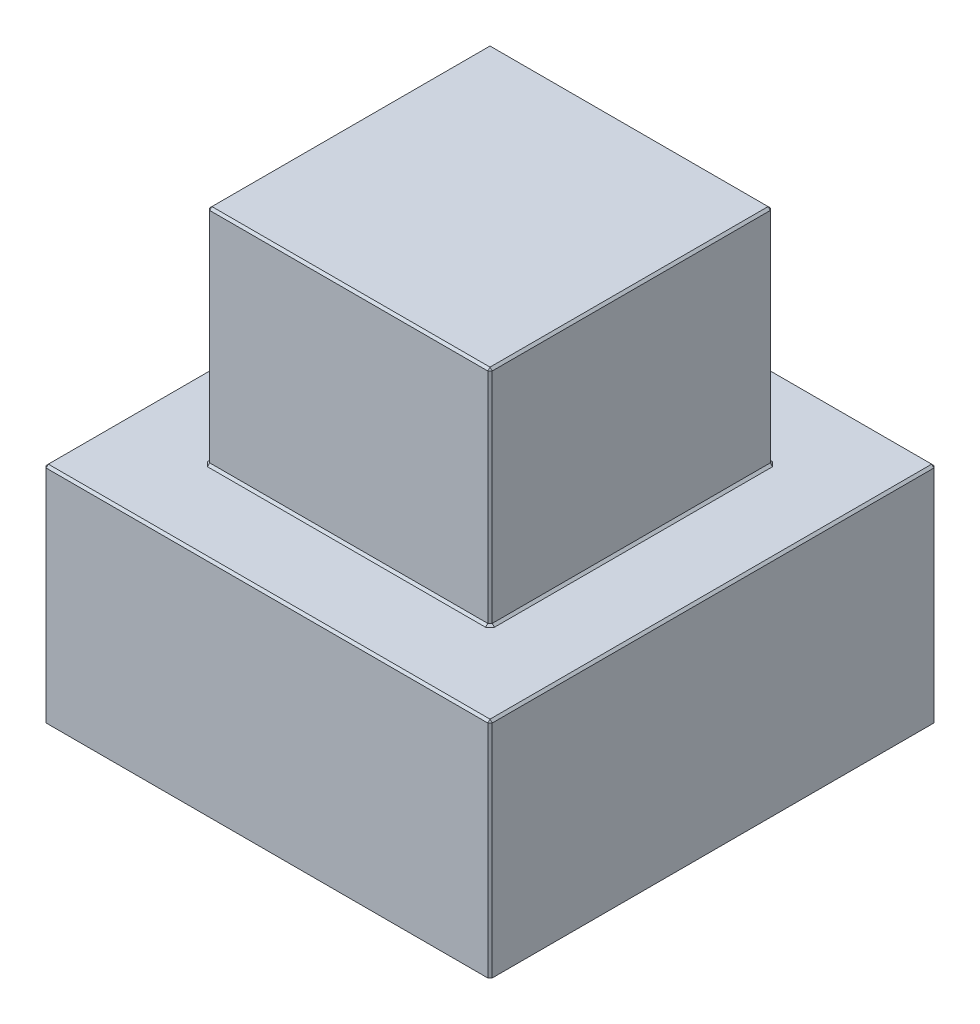
from build123d import *

# Parameters (mm, degrees)
ESQUISSE1_W        = 6
ESQUISSE1_H        = 6
BOSS_EXTRU_1_DEPTH = 3
ESQUISSE2_W        = 3.8
ESQUISSE2_H        = 3.8
BOSS_EXTRU_2_DEPTH = 3
CHANFREIN1_SIZE    = 0.03


with BuildPart() as part:
    # Esquisse1 → Boss.-Extru.1 (new body)
    with BuildSketch(Plane(origin=(0, 0, 0), x_dir=(1, 0, 0), z_dir=(0, 1, 0))):
        Rectangle(ESQUISSE1_W, ESQUISSE1_H)
    extrude(amount=BOSS_EXTRU_1_DEPTH)

    # Esquisse2 → Boss.-Extru.2 (add)
    with BuildSketch(Plane(origin=(0, 3, 0), x_dir=(1, 0, 0), z_dir=(0, 1, 0))):
        Rectangle(ESQUISSE2_W, ESQUISSE2_H)
    extrude(amount=BOSS_EXTRU_2_DEPTH)

    # Chanfrein1
    chanfrein1_edges = [part.edges().sort_by_distance(p)[0] for p in [
        (-3, 3, 0),
        (1.9, 3, 0),
        (1.9, 4.5, 1.9),
        (0, 3, 3),
        (0, 3, -1.9),
        (1.9, 4.5, -1.9),
        (-1.9, 3, 0),
        (-1.9, 4.5, -1.9),
        (0, 3, 1.9),
        (-1.9, 4.5, 1.9),
        (1.9, 6, 0),
        (0, 6, -1.9),
        (-1.9, 6, 0),
        (0, 6, 1.9),
        (3, 3, 0),
        (3, 1.5, 3),
        (-3, 1.5, 3),
        (-3, 1.5, -3),
        (3, 1.5, -3),
        (0, 3, -3),
    ]]
    chamfer(chanfrein1_edges, length=CHANFREIN1_SIZE)


solid = part.part
